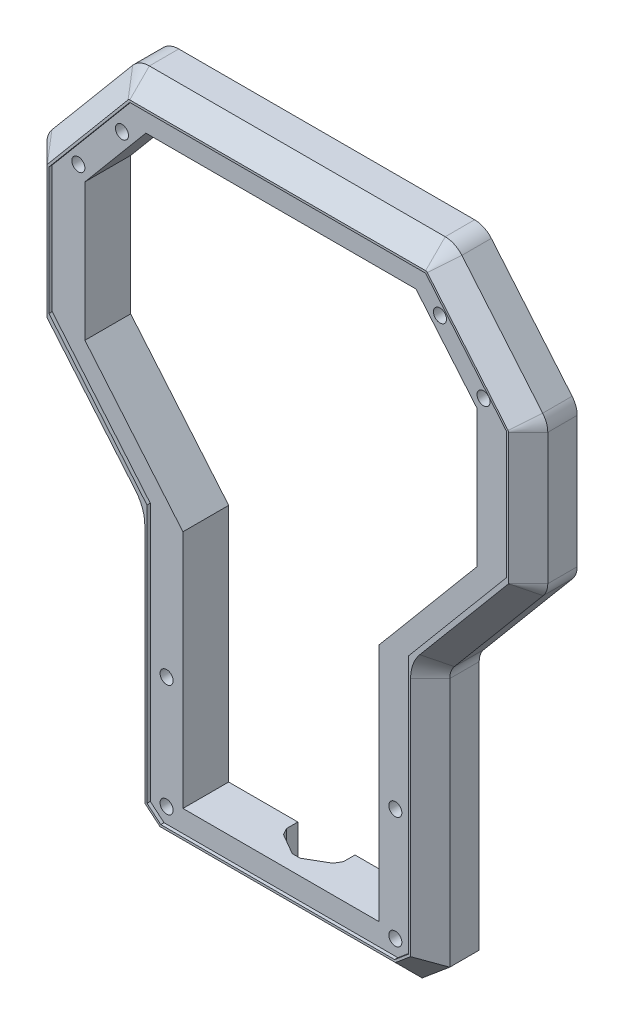
from build123d import *

# Parameters (mm, degrees)
RESSALTO_EXTRUS_O1_DEPTH = 22.5
CHANFRO1_SIZE            = 9
CORTE_EXTRUS_O1_REACH    = 24.5
ESBO_O3_W                = 1139.230904301
ESBO_O3_H                = 709.798033895
CORTE_EXTRUS_O5_DEPTH    = 1.5
ESBO_O5_R                = 3
CORTE_EXTRUS_O6_DEPTH    = 22
CORTE_EXTRUS_O8_DEPTH    = 10
CORTE_EXTRUS_O12_DEPTH   = 15
ESBO_O13_R               = 10.5
CORTE_EXTRUS_O13_DEPTH   = 5


with BuildPart() as part:
    # Esboço1 → Ressalto-extrusão1 (new body, symmetric)
    with BuildSketch(Plane.XY):
        with BuildLine():
            Line((-57.319579452, -8.082215343), (57.319579452, -8.082215343))
            Line((57.319579452, -8.082215343), (70, 2.557920862))
            Line((70, 2.557920862), (70, 117.296691049))
            ThreePointArc((70, 117.296691049), (70.546863139, 120.39810603), (72.121492792, 123.125444592))
            Line((72.121492792, 123.125444592), (112.878507208, 171.697762944))
            ThreePointArc((112.878507208, 171.697762944), (114.453136861, 174.425101506), (115, 177.526516487))
            Line((115, 177.526516487), (115, 237.712528581))
            ThreePointArc((115, 237.712528581), (114.396926208, 241.132730014), (112.660444431, 244.140404678))
            Line((112.660444431, 244.140404678), (75.567830361, 288.345660754))
            ThreePointArc((75.567830361, 288.345660754), (72.133568548, 290.980862527), (67.90738593, 291.917784657))
            Line((67.90738593, 291.917784657), (-67.90738593, 291.917784657))
            ThreePointArc((-67.90738593, 291.917784657), (-72.133568548, 290.980862527), (-75.567830361, 288.345660754))
            Line((-75.567830361, 288.345660754), (-112.660444431, 244.140404678))
            ThreePointArc((-112.660444431, 244.140404678), (-114.396926208, 241.132730014), (-115, 237.712528581))
            Line((-115, 237.712528581), (-115, 177.526516487))
            ThreePointArc((-115, 177.526516487), (-114.453136861, 174.425101506), (-112.878507208, 171.697762944))
            Line((-112.878507208, 171.697762944), (-72.121492792, 123.125444592))
            ThreePointArc((-72.121492792, 123.125444592), (-70.546863139, 120.39810603), (-70, 117.296691049))
            Line((-70, 117.296691049), (-70, 2.557920862))
            Line((-70, 2.557920862), (-57.319579452, -8.082215343))
        make_face()
        Polygon((-90, 175.546696324), (-90, 238.538123078), (-61.99113828, 271.917784657), (61.99113828, 271.917784657), (90, 238.538123078), (90, 175.546696324), (45, 121.917784657), (45, 11.917784657), (-45, 11.917784657), (-45, 121.917784657), align=None, mode=Mode.SUBTRACT)
    extrude(amount=RESSALTO_EXTRUS_O1_DEPTH, both=True)

    # Chanfro1
    chanfro1_edges = [part.edges().sort_by_distance(p)[0] for p in [
        (0, -8.082215343, 22.5),
        (63.659789726, -2.76214724, 22.5),
        (70, 59.927305955, 22.5),
        (70.546863139, 120.39810603, 22.5),
        (92.5, 147.411603768, 22.5),
        (114.453136861, 174.425101506, 22.5),
        (115, 207.619522534, 22.5),
        (114.396926208, 241.132730014, 22.5),
        (94.114137396, 266.243032716, 22.5),
        (72.133568548, 290.980862527, 22.5),
        (0, 291.917784657, 22.5),
        (-72.133568548, 290.980862527, 22.5),
        (-94.114137396, 266.243032716, 22.5),
        (-114.396926208, 241.132730014, 22.5),
        (-115, 207.619522534, 22.5),
        (-114.453136861, 174.425101506, 22.5),
        (-92.5, 147.411603768, 22.5),
        (-70.546863139, 120.39810603, 22.5),
        (-70, 59.927305955, 22.5),
        (-63.659789726, -2.76214724, 22.5),
    ]]
    chamfer(chanfro1_edges, length=CHANFRO1_SIZE)

    # Esboço3 → Corte-extrusão1 (cut, up to next)
    with BuildSketch(Plane.XY, mode=Mode.PRIVATE) as corte_extrus_o1_sk1:
        with Locations((-153.157436203, 152.53565808)):
            Rectangle(ESBO_O3_W, ESBO_O3_H)
    corte_extrus_o1_tool1 = extrude(corte_extrus_o1_sk1.sketch, amount=-CORTE_EXTRUS_O1_REACH, mode=Mode.PRIVATE) & part.part
    add(corte_extrus_o1_tool1.solids().sort_by_distance((-153.157436, 152.535658, 0))[0], mode=Mode.SUBTRACT)

    # Esboço4 → Corte-extrusão5 (cut)
    with BuildSketch(Plane.XY.offset(22.5)):
        Polygon((-60, 7.220997444), (-53.679877109, 1.917784657), (53.679877109, 1.917784657), (60, 7.220997444), (60, 125.792574104), (105, 179.421485771), (105, 237.712528581), (67.90738593, 281.917784657), (-67.90738593, 281.917784657), (-105, 237.712528581), (-105, 179.421485771), (-60, 125.792574104), align=None)
        Polygon((-90, 175.546696324), (-90, 238.538123078), (-61.99113828, 271.917784657), (61.99113828, 271.917784657), (90, 238.538123078), (90, 175.546696324), (45, 121.917784657), (45, 11.917784657), (-45, 11.917784657), (-45, 121.917784657), align=None, mode=Mode.SUBTRACT)
    extrude(amount=-CORTE_EXTRUS_O5_DEPTH, mode=Mode.SUBTRACT)

    # Esboço5 → Corte-extrusão6 (cut, through all)
    with BuildSketch(Plane.XY.offset(21)):
        with Locations((-93, 244)):
            Circle(ESBO_O5_R)
        with Locations((-52.5, 60.396230411)):
            Circle(ESBO_O5_R)
        with Locations((-73, 266.917784657)):
            Circle(ESBO_O5_R)
        with Locations((-52.5, 8.917784657)):
            Circle(ESBO_O5_R)
        with Locations((52.5, 8.917784657)):
            Circle(ESBO_O5_R)
        with Locations((73, 266.917784657)):
            Circle(ESBO_O5_R)
        with Locations((52.5, 60.396230411)):
            Circle(ESBO_O5_R)
        with Locations((93, 244)):
            Circle(ESBO_O5_R)
    extrude(amount=-CORTE_EXTRUS_O6_DEPTH, mode=Mode.SUBTRACT)

    # Esboço7 → Corte-extrusão8 (cut)
    with BuildSketch(Plane(origin=(0, 0, 0), x_dir=(-1, 0, 0), z_dir=(0, 0, -1))):
        Polygon((-73, 270.959236541), (-76.5, 268.938510599), (-76.5, 264.897058715), (-73, 262.876332773), (-69.5, 264.897058715), (-69.5, 268.938510599), align=None)
        Polygon((73, 270.959236541), (69.5, 268.938510599), (69.5, 264.897058715), (73, 262.876332773), (76.5, 264.897058715), (76.5, 268.938510599), align=None)
        Polygon((-93, 248.041451884), (-96.5, 246.020725942), (-96.5, 241.979274058), (-93, 239.958548116), (-89.5, 241.979274058), (-89.5, 246.020725942), align=None)
        Polygon((-52.5, 64.437682295), (-56, 62.416956353), (-56, 58.375504468), (-52.5, 56.354778526), (-49, 58.375504468), (-49, 62.416956353), align=None)
        Polygon((-52.5, 12.959236541), (-56, 10.938510599), (-56, 6.897058715), (-52.5, 4.876332773), (-49, 6.897058715), (-49, 10.938510599), align=None)
        Polygon((52.5, 12.959236541), (49, 10.938510599), (49, 6.897058715), (52.5, 4.876332773), (56, 6.897058715), (56, 10.938510599), align=None)
        Polygon((52.5, 64.437682295), (49, 62.416956353), (49, 58.375504468), (52.5, 56.354778526), (56, 58.375504468), (56, 62.416956353), align=None)
        Polygon((93, 248.041451884), (89.5, 246.020725942), (89.5, 241.979274058), (93, 239.958548116), (96.5, 241.979274058), (96.5, 246.020725942), align=None)
    extrude(amount=-CORTE_EXTRUS_O8_DEPTH, mode=Mode.SUBTRACT)

    # Esboço12 → Corte-extrusão12 (cut)
    with BuildSketch(Plane(origin=(0, 11.917784657, 0), x_dir=(1, 0, 0), z_dir=(0, 1, 0))):
        Polygon((-1.905573841, 14.34102327), (-11.457834044, 8.82602327), (-13.237834044, 5.742972833), (-13.237834044, -5.287027167), (-11.459750431, -8.366758325), (-1.915917658, -13.876892746), (1.640249569, -13.876892746), (11.220862954, -8.34552303), (12.986686363, -5.287027167), (12.986686363, 5.742972833), (11.206686363, 8.82602327), (1.654426159, 14.34102327), align=None)
    extrude(amount=-CORTE_EXTRUS_O12_DEPTH, mode=Mode.SUBTRACT)

    # Esboço13 → Corte-extrusão13 (cut)
    with BuildSketch(Plane.XZ.offset(8.082215343)):
        Circle(ESBO_O13_R)
    extrude(amount=-CORTE_EXTRUS_O13_DEPTH, mode=Mode.SUBTRACT)


solid = part.part
